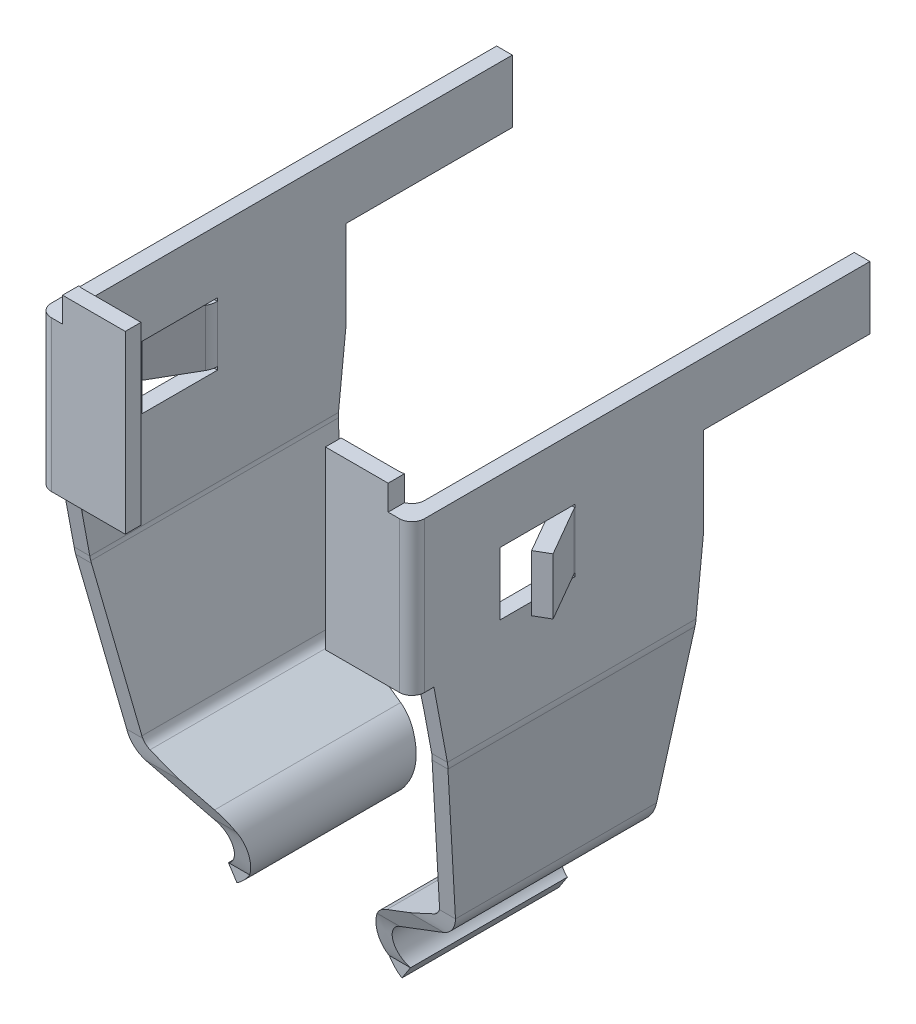
from build123d import *

# Parameters (mm, degrees)
DODANIE_WYCI_GNI_CIE1_DEPTH = 7.3
DODANIE_WYCI_GNI_CIE2_DEPTH = 0.25
SZKIC5_W                    = 1.2
SZKIC5_H                    = 1
WYTNIJ_WYCI_GNI_CIE2_DEPTH  = 12.167282267
WYTNIJ_WYCI_GNI_CIE3_DEPTH  = 12.167282285
ZAOKR_GLENIE1_R             = 0.2
ZAOKR_GLENIE2_R             = 0.2
DODANIE_WYCI_GNI_CIE3_START = 0.05
DODANIE_WYCI_GNI_CIE3_DEPTH = 0.9


with BuildPart() as part:
    # Szkic1 → Dodanie-wyci_gni_cie1 (new body)
    with BuildSketch(Plane.XY):
        with BuildLine():
            Line((1.405116335, 4.204317468), (1.057183583, 1.728647296))
            ThreePointArc((1.057183583, 1.728647296), (1.021953073, 1.640341325), (0.949928069, 1.578280612))
            Line((0.949928069, 1.578280612), (0.058921545, 1.124290112))
            ThreePointArc((0.058921545, 1.124290112), (-0.295093828, 0.579154241), (0, 0))
            Line((0, 0), (0.136159757, 0.209667643))
            ThreePointArc((0.136159757, 0.209667643), (-0.045436444, 0.566070253), (0.17241917, 0.901538481))
            Line((0.17241917, 0.901538481), (1.063425694, 1.355528981))
            ThreePointArc((1.063425694, 1.355528981), (1.225481952, 1.495165587), (1.3047506, 1.693854021))
            Line((1.3047506, 1.693854021), (1.652683352, 4.169524193))
            ThreePointArc((1.652683352, 4.169524193), (1.658155338, 4.221586663), (1.659982301, 4.273904019))
            Line((1.659982301, 4.273904019), (1.659982301, 5.42145891))
            Line((1.659982301, 5.42145891), (1.659982301, 7.82145891))
            Line((1.659982301, 7.82145891), (1.409982301, 7.82145891))
            Line((1.409982301, 7.82145891), (1.409982301, 5.42145891))
            Line((1.409982301, 5.42145891), (1.409982301, 4.273904019))
            ThreePointArc((1.409982301, 4.273904019), (1.408764326, 4.239025782), (1.405116335, 4.204317468))
        make_face()
    extrude(amount=DODANIE_WYCI_GNI_CIE1_DEPTH)

    # Szkic2 → Dodanie-wyci_gni_cie2 (add)
    with BuildSketch(Plane.XY.offset(7.3)):
        Polygon((1.355163819, 5.42145891), (1.655163819, 5.42145891), (1.655163819, 7.82145891), (1.355163819, 7.82145891), (1.280163818, 7.82145891), (1.280163818, 8.22145891), (0.280163815, 8.22145891), (0.280163815, 5.42145891), align=None)
    extrude(amount=-DODANIE_WYCI_GNI_CIE2_DEPTH)

    # Szkic5 → Wytnij-wyci_gni_cie2 (cut, through all)
    with BuildSketch(Plane(origin=(1.659982301, 0, 0), x_dir=(0, 0, -1), z_dir=(1, 0, 0))):
        with BuildLine():
            Line((-7, -1.842302501), (-5.8, 0))
            Line((-5.8, 0), (-5.8, 0.209667643))
            add(Edge.make_bspline(
                [(-6.005730187, 0.901538481), (-6.000661096, 0.892167233), (-5.995576462, 0.881337895), (-5.985438419, 0.857142657), (-5.980355945, 0.843708737), (-5.970218955, 0.814640367), (-5.965135365, 0.798924265), (-5.954996083, 0.765680027), (-5.949912341, 0.74805828), (-5.939773265, 0.711434436), (-5.934690231, 0.69232914), (-5.929621877, 0.672765989), (-5.927093091, 0.663005221), (-5.924562549, 0.653110489), (-5.922033629, 0.643125228), (-5.916965008, 0.623112133), (-5.911881046, 0.602649314), (-5.901741778, 0.5615423), (-5.89665792, 0.540782481), (-5.891588534, 0.520180818), (-5.889059233, 0.509901898), (-5.886528348, 0.499640559), (-5.883999416, 0.489441806), (-5.87893077, 0.469000815), (-5.873848413, 0.448725956), (-5.863710855, 0.409221102), (-5.858626574, 0.389880105), (-5.853557107, 0.371289718), (-5.851027765, 0.362014297), (-5.848496808, 0.352905444), (-5.84596738, 0.344003192), (-5.840897739, 0.326160734), (-5.835814098, 0.309076097), (-5.825686069, 0.277050711), (-5.820612684, 0.262016545), (-5.810374041, 0.23407951), (-5.805178757, 0.221153274), (-5.8, 0.209667643)],
                knots=[0, 0, 0, 0, 6.3766e-05, 6.3766e-05, 0.000127532, 0.000127532, 0.000191297, 0.000191297, 0.000255063, 0.000255063, 0.000318829, 0.000318829, 0.000318829, 0.000350576, 0.000350576, 0.000350576, 0.000414342, 0.000414342, 0.000478108, 0.000478108, 0.000478108, 0.000509855, 0.000509855, 0.000509855, 0.000573621, 0.000573621, 0.000637387, 0.000637387, 0.000637387, 0.000669134, 0.000669134, 0.000669134, 0.0007329, 0.0007329, 0.000796552, 0.000796552, 0.000861705, 0.000861705, 0.000861705, 0.000861705], degree=3))
            Line((-6.005730187, 0.901538481), (-6.192832907, 1.355528981))
            add(Edge.make_bspline(
                [(-6.251204765, 1.693854021), (-6.231580916, 1.550045034), (-6.212456756, 1.421458516), (-6.192832907, 1.355528981)],
                knots=[0, 0, 0, 0, 1, 1, 1, 1], degree=3))
            Line((-6.251204765, 1.693854021), (-6.718961566, 4.169524193))
            add(Edge.make_bspline(
                [(-6.735289358, 4.273904019), (-6.732562201, 4.256406846), (-6.729834153, 4.238907143), (-6.724392226, 4.20409032), (-6.72167633, 4.186759916), (-6.718961566, 4.169524193)],
                knots=[0, 0, 0, 0, 5.3125e-05, 5.3125e-05, 0.000105995, 0.000105995, 0.000105995, 0.000105995], degree=3))
            Line((-6.735289358, 4.273904019), (-7.3, 4.273904019))
            Line((-7.3, 4.273904019), (-7.3, 5.42145891))
            Line((-7.3, 5.42145891), (-10.052370219, -0.174444269))
            Line((-10.052370219, -0.174444269), (-7, -1.842302501))
        make_face()
        with BuildLine():
            Line((-3.3, 0.209667643), (-3.3, 0))
            Line((-3.3, 0), (0.677517739, -1.842302501))
            Line((0.677517739, -1.842302501), (2.05755561, 3.652844369))
            Line((2.05755561, 3.652844369), (0, 6.82145891))
            Line((0, 6.82145891), (0, 4.273904019))
            Line((0, 4.273904019), (-2.771358189, 4.273904019))
            add(Edge.make_bspline(
                [(-2.780586941, 4.169524193), (-2.77751069, 4.20409107), (-2.77443444, 4.238997434), (-2.771358189, 4.273904019)],
                knots=[0, 0, 0, 0, 1, 1, 1, 1], degree=3))
            Line((-2.780586941, 4.169524193), (-3.04497122, 1.693854021))
            add(Edge.make_bspline(
                [(-3.077964009, 1.355528981), (-3.06687125, 1.421464567), (-3.056063979, 1.550031836), (-3.04497122, 1.693854021)],
                knots=[0, 0, 0, 0, 1, 1, 1, 1], degree=3))
            Line((-3.077964009, 1.355528981), (-3.183717721, 0.901538481))
            add(Edge.make_bspline(
                [(-3.3, 0.209667643), (-3.29030981, 0.24769062), (-3.28061962, 0.30133568), (-3.26123924, 0.42574366), (-3.25154905, 0.496352759), (-3.23216867, 0.635787746), (-3.22247848, 0.704441234), (-3.203098101, 0.821541736), (-3.193407911, 0.869843965), (-3.183717721, 0.901538481)],
                knots=[0, 0, 0, 0, 0.25, 0.25, 0.5, 0.5, 0.75, 0.75, 1, 1, 1, 1], degree=3))
        make_face()
        with Locations((-5.3, 6.32145891)):
            Rectangle(SZKIC5_W, SZKIC5_H)
    extrude(amount=-WYTNIJ_WYCI_GNI_CIE2_DEPTH, mode=Mode.SUBTRACT)

    # Szkic5_5 → Wytnij-wyci_gni_cie3 (cut, through all)
    with BuildSketch(Plane(origin=(1.659982301, 0, 0), x_dir=(0, 0, -1), z_dir=(1, 0, 0))):
        Polygon((-6.95, 5.42145891), (-7.3, 5.42145891), (-7.3, 4.273904019), (-6.735289358, 4.273904019), align=None)
        Polygon((0, 4.273904019), (0, 6.82145891), (-2.65, 6.82145891), (-2.65, 5.42145891), (-2.771358189, 4.273904019), align=None)
    extrude(amount=-WYTNIJ_WYCI_GNI_CIE3_DEPTH, mode=Mode.SUBTRACT)

    # Zaokr_glenie1
    zaokr_glenie1_edges = [part.edges().sort_by_distance(p)[0] for p in [
        (1.659982301, 6.62145891, 7.3),
    ]]
    fillet(zaokr_glenie1_edges, radius=ZAOKR_GLENIE1_R)

    # Zaokr_glenie2
    zaokr_glenie2_edges = [part.edges().sort_by_distance(p)[0] for p in [
        (1.409982301, 6.62145891, 7.05),
    ]]
    fillet(zaokr_glenie2_edges, radius=ZAOKR_GLENIE2_R)

    # Szkic6 → Dodanie-wyci_gni_cie3 (add)
    with BuildSketch(Plane(origin=(0, 5.82145891, 0), x_dir=(1, 0, 0), z_dir=(0, 1, 0)).offset(DODANIE_WYCI_GNI_CIE3_START)):
        with BuildLine():
            Line((1.659982301, -4.7), (1.409982301, -4.7))
            ThreePointArc((1.409982301, -4.7), (1.420204553, -4.777645714), (1.45017468, -4.85))
            Line((1.45017468, -4.85), (1.904359787, -5.636671682))
            Line((1.904359787, -5.636671682), (2.120866138, -5.511671682))
            Line((2.120866138, -5.511671682), (1.66668103, -4.725))
            ThreePointArc((1.66668103, -4.725), (1.661686009, -4.712940952), (1.659982301, -4.7))
        make_face()
    extrude(amount=DODANIE_WYCI_GNI_CIE3_DEPTH)


with BuildPart() as body_2:
    # Lustro2: mirrored copy
    add(part.part.mirror(Plane.ZY.offset(1.315017699)))


solid = Compound([part.part, body_2.part])
